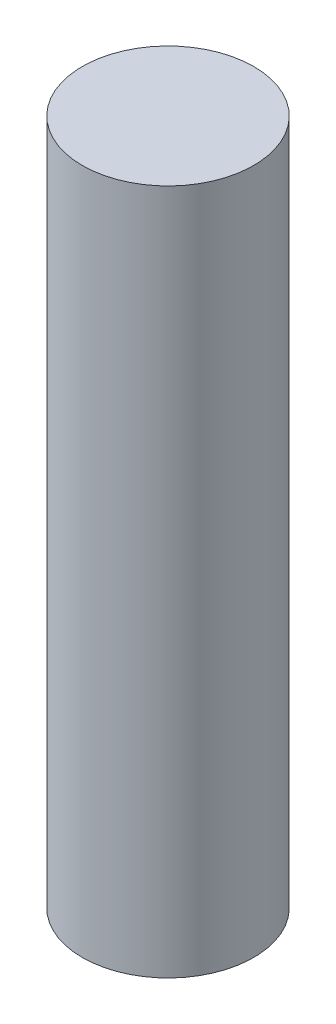
from build123d import *

# Parameters (mm, degrees)
SKETCH1_R           = 5
BOSS_EXTRUDE1_DEPTH = 20


with BuildPart() as part:
    # Sketch1 → Boss-Extrude1 (new body, symmetric)
    with BuildSketch(Plane(origin=(0, 0, 0), x_dir=(1, 0, 0), z_dir=(0, 1, 0))):
        Circle(SKETCH1_R)
    extrude(amount=BOSS_EXTRUDE1_DEPTH, both=True)


solid = part.part
